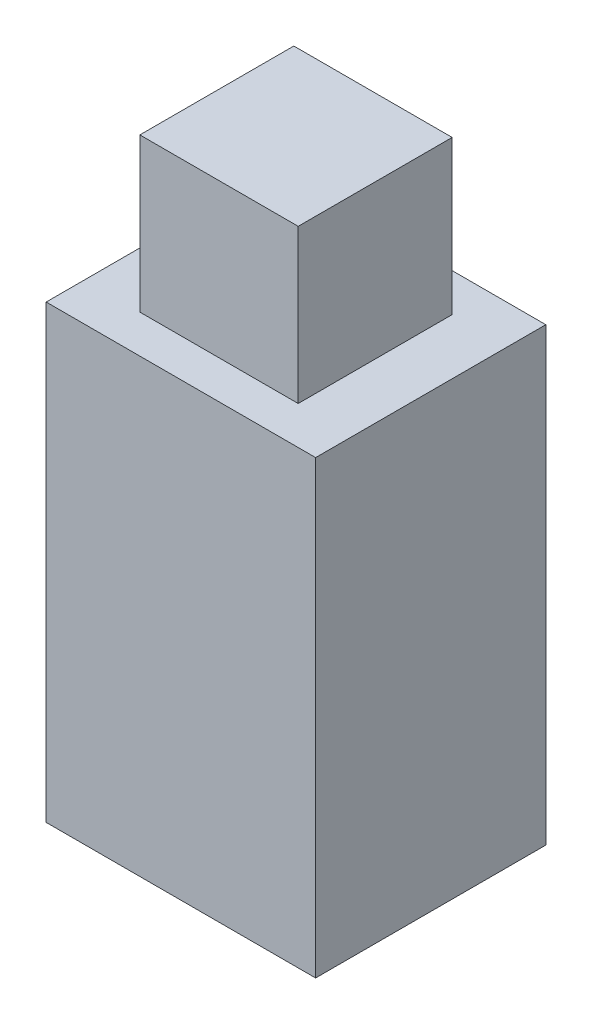
from build123d import *

# Parameters (mm, degrees)
SKETCH1_W           = 70.230746482
SKETCH1_H           = 117.476103032
BOSS_EXTRUDE1_DEPTH = 60
SKETCH2_W           = 41.272842477
SKETCH2_H           = 40.131406686
BOSS_EXTRUDE2_DEPTH = 40


with BuildPart() as part:
    # Sketch1 → Boss-Extrude1 (new body)
    with BuildSketch(Plane.XY):
        with Locations((-16.436427192, -13.121363424)):
            Rectangle(SKETCH1_W, SKETCH1_H)
    extrude(amount=BOSS_EXTRUDE1_DEPTH)

    # Sketch2 → Boss-Extrude2 (add)
    with BuildSketch(Plane(origin=(0, 45.616688092, 0), x_dir=(1, 0, 0), z_dir=(0, 1, 0))):
        with Locations((-16.436427192, -30)):
            Rectangle(SKETCH2_W, SKETCH2_H)
    extrude(amount=BOSS_EXTRUDE2_DEPTH)


solid = part.part
